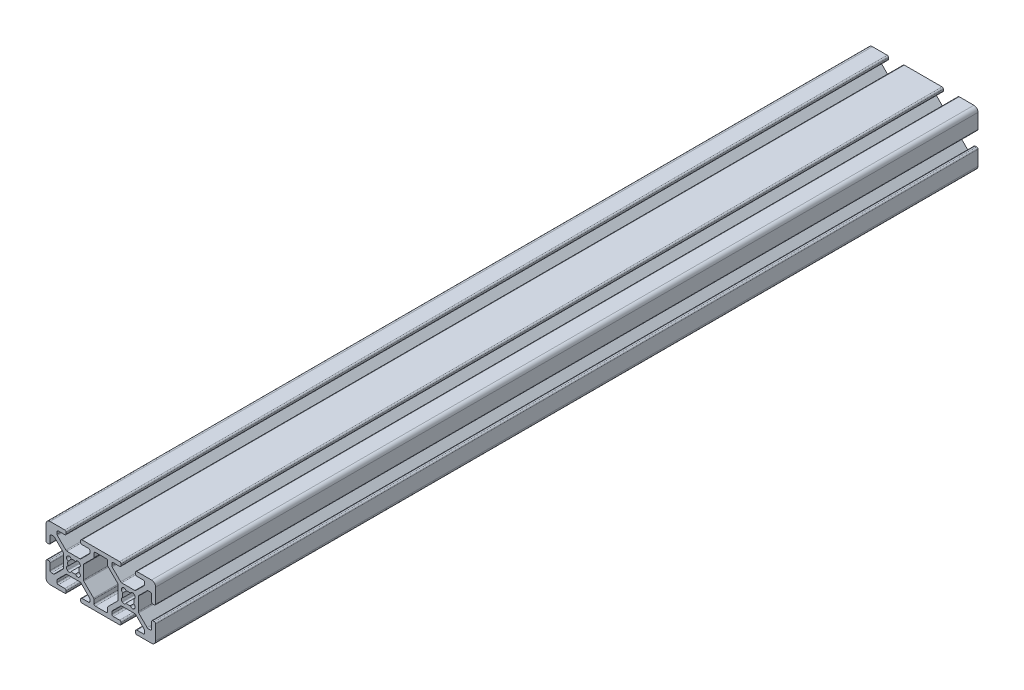
from build123d import *

# Parameters (mm, degrees)
EXTRUDE1_DEPTH = 300


with BuildPart() as part:
    # Sketch1 → Extrude1 (new body)
    with BuildSketch(Plane.XY):
        with BuildLine():
            Line((-22.383919339, -3.655), (-17.616080661, -3.655))
            ThreePointArc((-17.616080661, -3.655), (-17.421677478, -3.693669197), (-17.256870417, -3.803789755))
            Line((-17.256870417, -3.803789755), (-14.153789755, -6.906870417))
            ThreePointArc((-14.153789755, -6.906870417), (-14.043669197, -7.071677478), (-14.005, -7.266080661))
            Line((-14.005, -7.266080661), (-14.005, -7.992))
            ThreePointArc((-14.005, -7.992), (-14.153789755, -8.351210245), (-14.513, -8.5))
            Line((-14.513, -8.5), (-16.862, -8.5))
            ThreePointArc((-16.862, -8.5), (-17.221210245, -8.648789755), (-17.37, -9.008))
            Line((-17.37, -9.008), (-17.37, -9.492))
            ThreePointArc((-17.37, -9.492), (-17.221210245, -9.851210245), (-16.862, -10))
            Line((-16.862, -10), (-3.138, -10))
            ThreePointArc((-3.138, -10), (-2.778789755, -9.851210245), (-2.63, -9.492))
            Line((-2.63, -9.492), (-2.63, -9.008))
            ThreePointArc((-2.63, -9.008), (-2.778789755, -8.648789755), (-3.138, -8.5))
            Line((-3.138, -8.5), (-5.487, -8.5))
            ThreePointArc((-5.487, -8.5), (-5.846210245, -8.351210245), (-5.995, -7.992))
            Line((-5.995, -7.992), (-5.995, -7.266080661))
            ThreePointArc((-5.995, -7.266080661), (-5.956330803, -7.071677478), (-5.846210245, -6.906870417))
            Line((-5.846210245, -6.906870417), (-2.743129583, -3.803789755))
            ThreePointArc((-2.743129583, -3.803789755), (-2.578322522, -3.693669197), (-2.383919339, -3.655))
            Line((-2.383919339, -3.655), (2.383919339, -3.655))
            ThreePointArc((2.383919339, -3.655), (2.578322522, -3.693669197), (2.743129583, -3.803789755))
            Line((2.743129583, -3.803789755), (5.846210245, -6.906870417))
            ThreePointArc((5.846210245, -6.906870417), (5.956330803, -7.071677478), (5.995, -7.266080661))
            Line((5.995, -7.266080661), (5.995, -7.992))
            ThreePointArc((5.995, -7.992), (5.846210245, -8.351210245), (5.487, -8.5))
            Line((5.487, -8.5), (3.138, -8.5))
            ThreePointArc((3.138, -8.5), (2.778789755, -8.648789755), (2.63, -9.008))
            Line((2.63, -9.008), (2.63, -9.492))
            ThreePointArc((2.63, -9.492), (2.778789755, -9.851210245), (3.138, -10))
            Line((3.138, -10), (8.5, -10))
            ThreePointArc((8.5, -10), (9.560660172, -9.560660172), (10, -8.5))
            Line((10, -8.5), (10, -3.138))
            ThreePointArc((10, -3.138), (9.851210245, -2.778789755), (9.492, -2.63))
            Line((9.492, -2.63), (9.008, -2.63))
            ThreePointArc((9.008, -2.63), (8.648789755, -2.778789755), (8.5, -3.138))
            Line((8.5, -3.138), (8.5, -5.487))
            ThreePointArc((8.5, -5.487), (8.351210245, -5.846210245), (7.992, -5.995))
            Line((7.992, -5.995), (7.266080661, -5.995))
            ThreePointArc((7.266080661, -5.995), (7.071677478, -5.956330803), (6.906870417, -5.846210245))
            Line((6.906870417, -5.846210245), (3.803789755, -2.743129583))
            ThreePointArc((3.803789755, -2.743129583), (3.693669197, -2.578322522), (3.655, -2.383919339))
            Line((3.655, -2.383919339), (3.655, 2.383919339))
            ThreePointArc((3.655, 2.383919339), (3.693669197, 2.578322522), (3.803789755, 2.743129583))
            Line((3.803789755, 2.743129583), (6.906870417, 5.846210245))
            ThreePointArc((6.906870417, 5.846210245), (7.071677478, 5.956330803), (7.266080661, 5.995))
            Line((7.266080661, 5.995), (7.992, 5.995))
            ThreePointArc((7.992, 5.995), (8.351210245, 5.846210245), (8.5, 5.487))
            Line((8.5, 5.487), (8.5, 3.138))
            ThreePointArc((8.5, 3.138), (8.648789755, 2.778789755), (9.008, 2.63))
            Line((9.008, 2.63), (9.492, 2.63))
            ThreePointArc((9.492, 2.63), (9.851210245, 2.778789755), (10, 3.138))
            Line((10, 3.138), (10, 8.5))
            ThreePointArc((10, 8.5), (9.560660172, 9.560660172), (8.5, 10))
            Line((8.5, 10), (3.138, 10))
            ThreePointArc((3.138, 10), (2.778789755, 9.851210245), (2.63, 9.492))
            Line((2.63, 9.492), (2.63, 9.008))
            ThreePointArc((2.63, 9.008), (2.778789755, 8.648789755), (3.138, 8.5))
            Line((3.138, 8.5), (5.487, 8.5))
            ThreePointArc((5.487, 8.5), (5.846210245, 8.351210245), (5.995, 7.992))
            Line((5.995, 7.992), (5.995, 7.266080661))
            ThreePointArc((5.995, 7.266080661), (5.956330803, 7.071677478), (5.846210245, 6.906870417))
            Line((5.846210245, 6.906870417), (2.743129583, 3.803789755))
            ThreePointArc((2.743129583, 3.803789755), (2.578322522, 3.693669197), (2.383919339, 3.655))
            Line((2.383919339, 3.655), (-2.383919339, 3.655))
            ThreePointArc((-2.383919339, 3.655), (-2.578322522, 3.693669197), (-2.743129583, 3.803789755))
            Line((-2.743129583, 3.803789755), (-5.846210245, 6.906870417))
            ThreePointArc((-5.846210245, 6.906870417), (-5.956330803, 7.071677478), (-5.995, 7.266080661))
            Line((-5.995, 7.266080661), (-5.995, 7.992))
            ThreePointArc((-5.995, 7.992), (-5.846210245, 8.351210245), (-5.487, 8.5))
            Line((-5.487, 8.5), (-3.138, 8.5))
            ThreePointArc((-3.138, 8.5), (-2.778789755, 8.648789755), (-2.63, 9.008))
            Line((-2.63, 9.008), (-2.63, 9.492))
            ThreePointArc((-2.63, 9.492), (-2.778789755, 9.851210245), (-3.138, 10))
            Line((-3.138, 10), (-16.862, 10))
            ThreePointArc((-16.862, 10), (-17.221210245, 9.851210245), (-17.37, 9.492))
            Line((-17.37, 9.492), (-17.37, 9.008))
            ThreePointArc((-17.37, 9.008), (-17.221210245, 8.648789755), (-16.862, 8.5))
            Line((-16.862, 8.5), (-14.513, 8.5))
            ThreePointArc((-14.513, 8.5), (-14.153789755, 8.351210245), (-14.005, 7.992))
            Line((-14.005, 7.992), (-14.005, 7.266080661))
            ThreePointArc((-14.005, 7.266080661), (-14.043669197, 7.071677478), (-14.153789755, 6.906870417))
            Line((-14.153789755, 6.906870417), (-17.256870417, 3.803789755))
            ThreePointArc((-17.256870417, 3.803789755), (-17.421677478, 3.693669197), (-17.616080661, 3.655))
            Line((-17.616080661, 3.655), (-22.383919339, 3.655))
            ThreePointArc((-22.383919339, 3.655), (-22.578322522, 3.693669197), (-22.743129583, 3.803789755))
            Line((-22.743129583, 3.803789755), (-25.846210245, 6.906870417))
            ThreePointArc((-25.846210245, 6.906870417), (-25.956330803, 7.071677478), (-25.995, 7.266080661))
            Line((-25.995, 7.266080661), (-25.995, 7.992))
            ThreePointArc((-25.995, 7.992), (-25.846210245, 8.351210245), (-25.487, 8.5))
            Line((-25.487, 8.5), (-23.138, 8.5))
            ThreePointArc((-23.138, 8.5), (-22.778789755, 8.648789755), (-22.63, 9.008))
            Line((-22.63, 9.008), (-22.63, 9.492))
            ThreePointArc((-22.63, 9.492), (-22.778789755, 9.851210245), (-23.138, 10))
            Line((-23.138, 10), (-28.5, 10))
            ThreePointArc((-28.5, 10), (-29.560660172, 9.560660172), (-30, 8.5))
            Line((-30, 8.5), (-30, 3.138))
            ThreePointArc((-30, 3.138), (-29.851210245, 2.778789755), (-29.492, 2.63))
            Line((-29.492, 2.63), (-29.008, 2.63))
            ThreePointArc((-29.008, 2.63), (-28.648789755, 2.778789755), (-28.5, 3.138))
            Line((-28.5, 3.138), (-28.5, 5.487))
            ThreePointArc((-28.5, 5.487), (-28.351210245, 5.846210245), (-27.992, 5.995))
            Line((-27.992, 5.995), (-27.266080661, 5.995))
            ThreePointArc((-27.266080661, 5.995), (-27.071677478, 5.956330803), (-26.906870417, 5.846210245))
            Line((-26.906870417, 5.846210245), (-23.803789755, 2.743129583))
            ThreePointArc((-23.803789755, 2.743129583), (-23.693669197, 2.578322522), (-23.655, 2.383919339))
            Line((-23.655, 2.383919339), (-23.655, -2.383919339))
            ThreePointArc((-23.655, -2.383919339), (-23.693669197, -2.578322522), (-23.803789755, -2.743129583))
            Line((-23.803789755, -2.743129583), (-26.906870417, -5.846210245))
            ThreePointArc((-26.906870417, -5.846210245), (-27.071677478, -5.956330803), (-27.266080661, -5.995))
            Line((-27.266080661, -5.995), (-27.992, -5.995))
            ThreePointArc((-27.992, -5.995), (-28.351210245, -5.846210245), (-28.5, -5.487))
            Line((-28.5, -5.487), (-28.5, -3.138))
            ThreePointArc((-28.5, -3.138), (-28.648789755, -2.778789755), (-29.008, -2.63))
            Line((-29.008, -2.63), (-29.492, -2.63))
            ThreePointArc((-29.492, -2.63), (-29.851210245, -2.778789755), (-30, -3.138))
            Line((-30, -3.138), (-30, -8.5))
            ThreePointArc((-30, -8.5), (-29.560660172, -9.560660172), (-28.5, -10))
            Line((-28.5, -10), (-23.138, -10))
            ThreePointArc((-23.138, -10), (-22.778789755, -9.851210245), (-22.63, -9.492))
            Line((-22.63, -9.492), (-22.63, -9.008))
            ThreePointArc((-22.63, -9.008), (-22.778789755, -8.648789755), (-23.138, -8.5))
            Line((-23.138, -8.5), (-25.487, -8.5))
            ThreePointArc((-25.487, -8.5), (-25.846210245, -8.351210245), (-25.995, -7.992))
            Line((-25.995, -7.992), (-25.995, -7.266080661))
            ThreePointArc((-25.995, -7.266080661), (-25.956330803, -7.071677478), (-25.846210245, -6.906870417))
            Line((-25.846210245, -6.906870417), (-22.743129583, -3.803789755))
            ThreePointArc((-22.743129583, -3.803789755), (-22.578322522, -3.693669197), (-22.383919339, -3.655))
        make_face()
        with BuildLine():
            Line((-2.124900844, -2.304505966), (-2.304505966, -2.124900844))
            ThreePointArc((-2.304505966, -2.124900844), (-2.505938017, -1.356467811), (-1.935133506, -0.803976718))
            ThreePointArc((-1.935133506, -0.803976718), (-2.0955, 0), (-1.935133506, 0.803976718))
            ThreePointArc((-1.935133506, 0.803976718), (-2.505938017, 1.356467811), (-2.304505966, 2.124900844))
            Line((-2.304505966, 2.124900844), (-2.124900844, 2.304505966))
            ThreePointArc((-2.124900844, 2.304505966), (-1.356467811, 2.505938017), (-0.803976718, 1.935133506))
            ThreePointArc((-0.803976718, 1.935133506), (0, 2.0955), (0.803976718, 1.935133506))
            ThreePointArc((0.803976718, 1.935133506), (1.356467811, 2.505938017), (2.124900844, 2.304505966))
            Line((2.124900844, 2.304505966), (2.304505966, 2.124900844))
            ThreePointArc((2.304505966, 2.124900844), (2.505938017, 1.356467811), (1.935133506, 0.803976718))
            ThreePointArc((1.935133506, 0.803976718), (2.0955, 0), (1.935133506, -0.803976718))
            ThreePointArc((1.935133506, -0.803976718), (2.505938017, -1.356467811), (2.304505966, -2.124900844))
            Line((2.304505966, -2.124900844), (2.124900844, -2.304505966))
            ThreePointArc((2.124900844, -2.304505966), (1.356467811, -2.505938017), (0.803976718, -1.935133506))
            ThreePointArc((0.803976718, -1.935133506), (0, -2.0955), (-0.803976718, -1.935133506))
            ThreePointArc((-0.803976718, -1.935133506), (-1.356467811, -2.505938017), (-2.124900844, -2.304505966))
        make_face(mode=Mode.SUBTRACT)
        with BuildLine():
            Line((-12.505, -7.992), (-12.505, -6.644760318))
            ThreePointArc((-12.505, -6.644760318), (-12.543669197, -6.450357134), (-12.653789755, -6.285550073))
            Line((-12.653789755, -6.285550073), (-16.196210245, -2.743129583))
            ThreePointArc((-16.196210245, -2.743129583), (-16.306330803, -2.578322522), (-16.345, -2.383919339))
            Line((-16.345, -2.383919339), (-16.345, 2.383919339))
            ThreePointArc((-16.345, 2.383919339), (-16.306330803, 2.578322522), (-16.196210245, 2.743129583))
            Line((-16.196210245, 2.743129583), (-12.653789755, 6.285550073))
            ThreePointArc((-12.653789755, 6.285550073), (-12.543669197, 6.450357134), (-12.505, 6.644760318))
            Line((-12.505, 6.644760318), (-12.505, 7.992))
            ThreePointArc((-12.505, 7.992), (-12.356210245, 8.351210245), (-11.997, 8.5))
            Line((-11.997, 8.5), (-8.003, 8.5))
            ThreePointArc((-8.003, 8.5), (-7.643789755, 8.351210245), (-7.495, 7.992))
            Line((-7.495, 7.992), (-7.495, 6.644760318))
            ThreePointArc((-7.495, 6.644760318), (-7.456330803, 6.450357134), (-7.346210245, 6.285550073))
            Line((-7.346210245, 6.285550073), (-3.803789755, 2.743129583))
            ThreePointArc((-3.803789755, 2.743129583), (-3.693669197, 2.578322522), (-3.655, 2.383919339))
            Line((-3.655, 2.383919339), (-3.655, -2.383919339))
            ThreePointArc((-3.655, -2.383919339), (-3.693669197, -2.578322522), (-3.803789755, -2.743129583))
            Line((-3.803789755, -2.743129583), (-7.346210245, -6.285550073))
            ThreePointArc((-7.346210245, -6.285550073), (-7.456330803, -6.450357134), (-7.495, -6.644760318))
            Line((-7.495, -6.644760318), (-7.495, -7.992))
            ThreePointArc((-7.495, -7.992), (-7.643789755, -8.351210245), (-8.003, -8.5))
            Line((-8.003, -8.5), (-11.997, -8.5))
            ThreePointArc((-11.997, -8.5), (-12.356210245, -8.351210245), (-12.505, -7.992))
        make_face(mode=Mode.SUBTRACT)
        with BuildLine():
            Line((-22.124900844, -2.304505966), (-22.304505966, -2.124900844))
            ThreePointArc((-22.304505966, -2.124900844), (-22.505938017, -1.356467811), (-21.935133506, -0.803976718))
            ThreePointArc((-21.935133506, -0.803976718), (-22.0955, 0), (-21.935133506, 0.803976718))
            ThreePointArc((-21.935133506, 0.803976718), (-22.505938017, 1.356467811), (-22.304505966, 2.124900844))
            Line((-22.304505966, 2.124900844), (-22.124900844, 2.304505966))
            ThreePointArc((-22.124900844, 2.304505966), (-21.356467811, 2.505938017), (-20.803976718, 1.935133506))
            ThreePointArc((-20.803976718, 1.935133506), (-20, 2.0955), (-19.196023282, 1.935133506))
            ThreePointArc((-19.196023282, 1.935133506), (-18.643532189, 2.505938017), (-17.875099156, 2.304505966))
            Line((-17.875099156, 2.304505966), (-17.695494034, 2.124900844))
            ThreePointArc((-17.695494034, 2.124900844), (-17.494061983, 1.356467811), (-18.064866494, 0.803976718))
            ThreePointArc((-18.064866494, 0.803976718), (-17.9045, 0), (-18.064866494, -0.803976718))
            ThreePointArc((-18.064866494, -0.803976718), (-17.494061983, -1.356467811), (-17.695494034, -2.124900844))
            Line((-17.695494034, -2.124900844), (-17.875099156, -2.304505966))
            ThreePointArc((-17.875099156, -2.304505966), (-18.643532189, -2.505938017), (-19.196023282, -1.935133506))
            ThreePointArc((-19.196023282, -1.935133506), (-20, -2.0955), (-20.803976718, -1.935133506))
            ThreePointArc((-20.803976718, -1.935133506), (-21.356467811, -2.505938017), (-22.124900844, -2.304505966))
        make_face(mode=Mode.SUBTRACT)
    extrude(amount=-EXTRUDE1_DEPTH)


solid = part.part
